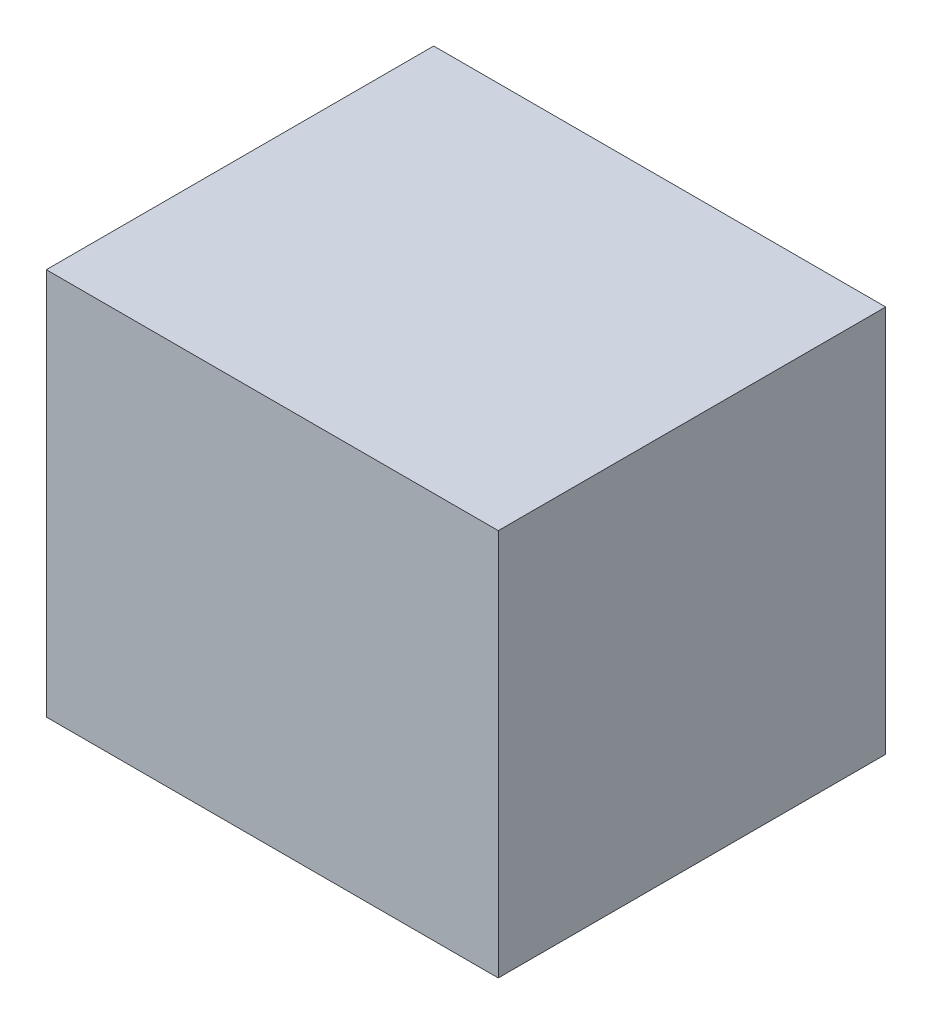
from build123d import *

# Parameters (mm, degrees)
SKETCH1_W           = 76.2
SKETCH1_H           = 76.2
BOSS_EXTRUDE1_DEPTH = 88.9


with BuildPart() as part:
    # Sketch1 → Boss-Extrude1 (new body)
    with BuildSketch(Plane(origin=(0, 0, 0), x_dir=(0, 0, -1), z_dir=(1, 0, 0))):
        Rectangle(SKETCH1_W, SKETCH1_H)
    extrude(amount=BOSS_EXTRUDE1_DEPTH)


solid = part.part
